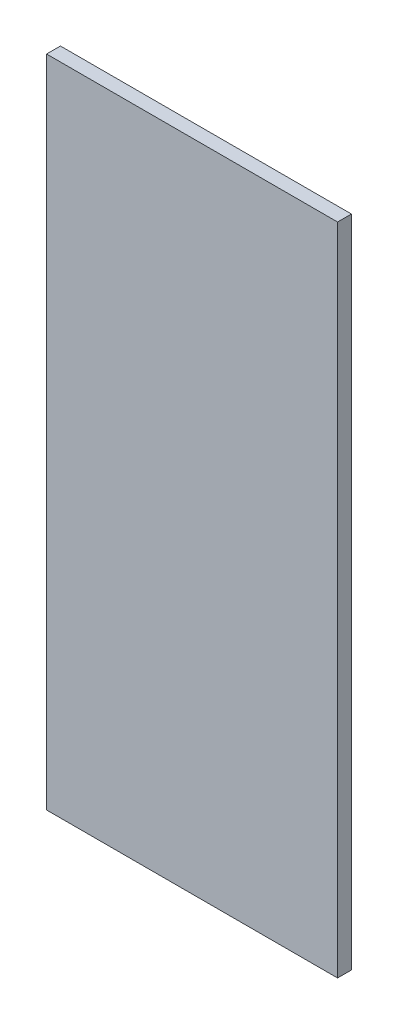
from build123d import *

# Parameters (mm, degrees)
SKETCH1_W           = 400
SKETCH1_H           = 900
BOSS_EXTRUDE1_DEPTH = 19.05


with BuildPart() as part:
    # Sketch1 → Boss-Extrude1 (new body)
    with BuildSketch(Plane.XY):
        with Locations((200, -450)):
            Rectangle(SKETCH1_W, SKETCH1_H)
    extrude(amount=BOSS_EXTRUDE1_DEPTH)


solid = part.part
